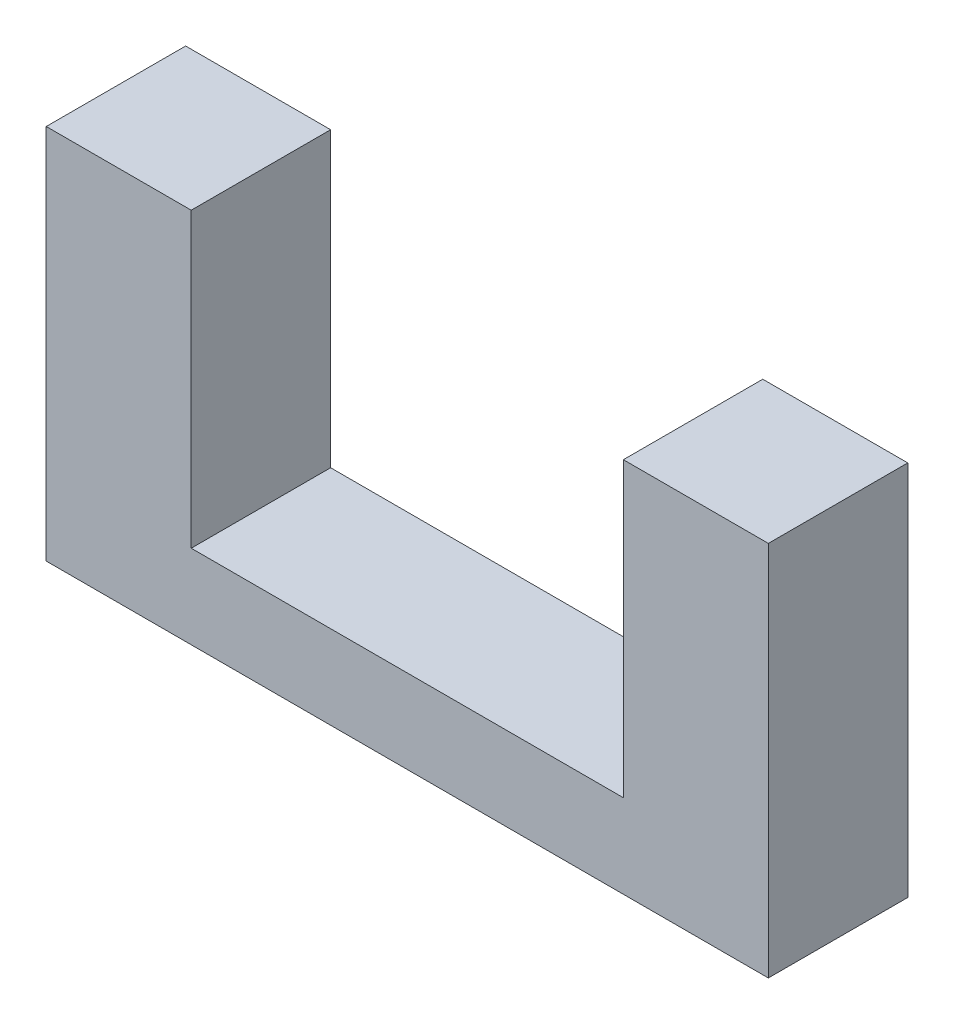
from build123d import *

# Parameters (mm, degrees)
BOSS_EXTRUDE1_DEPTH = 10


with BuildPart() as part:
    # Sketch1 → Boss-Extrude1 (new body)
    with BuildSketch(Plane.XY):
        Polygon((-15.5, 13.5), (-15.5, -7.5), (15.5, -7.5), (15.5, 13.5), (25.9, 13.5), (25.9, -13.5), (-25.9, -13.5), (-25.9, 13.5), align=None)
    extrude(amount=BOSS_EXTRUDE1_DEPTH)


solid = part.part
